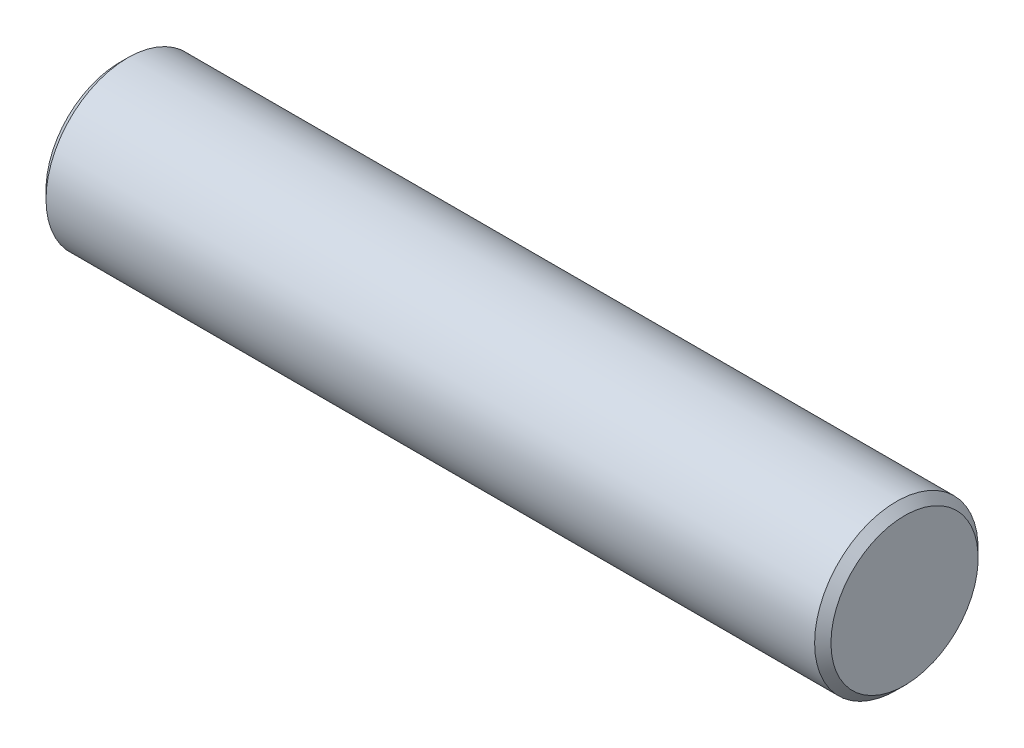
from build123d import *

# Parameters (mm, degrees)
SKETCH_1_W     = 24
SKETCH_1_H     = 2.5
CHAMFER_1_SIZE = 0.25


with BuildPart() as part:
    # Эскиз1 → Повернуть2 (revolve)
    with BuildSketch(Plane.XY):
        with Locations((12, 1.25)):
            Rectangle(SKETCH_1_W, SKETCH_1_H)
    revolve(axis=Axis((0, 0, 0), (1, 0, 0)))

    # Фаска1
    chamfer_1_edges = [part.edges().sort_by_distance(p)[0] for p in [
        (24, -2.5, 0),
        (0, -2.5, 0),
    ]]
    chamfer(chamfer_1_edges, length=CHAMFER_1_SIZE)


solid = part.part
